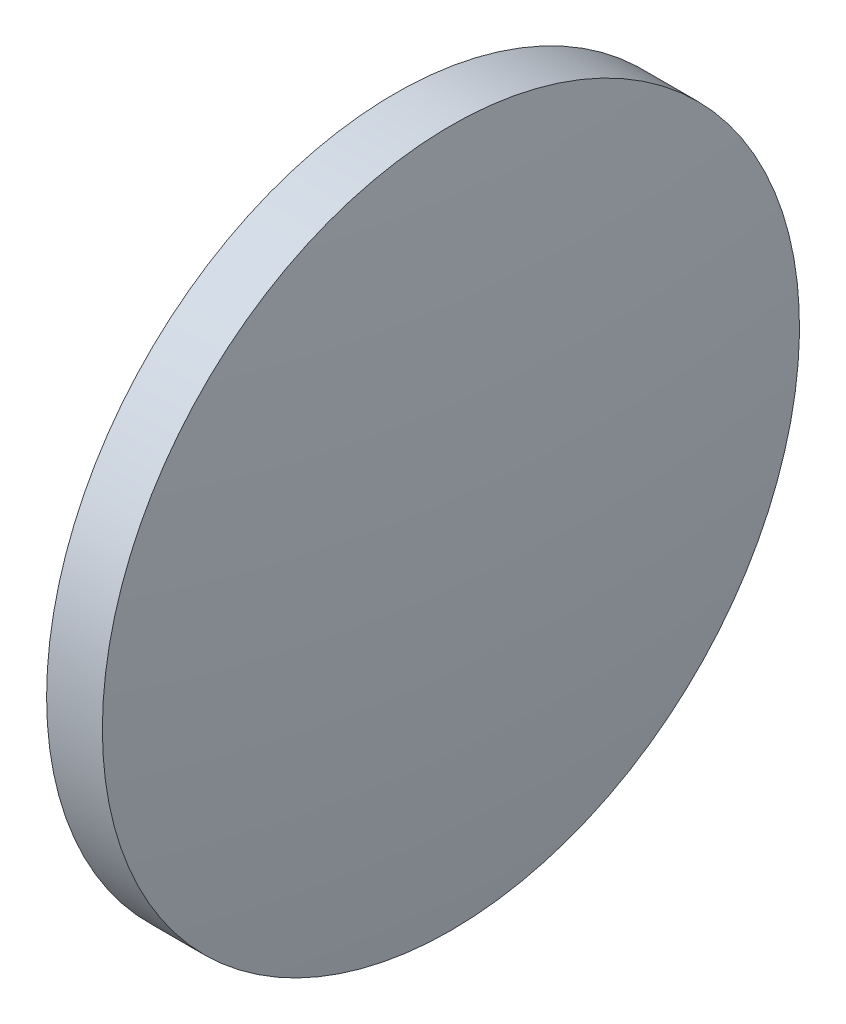
from build123d import *


with BuildPart() as part:
    # 草图1 → 旋转1 (revolve)
    with BuildSketch(Plane.XY, mode=Mode.PRIVATE) as revolve_1_sk:
        with BuildLine():
            Line((403.447923091, 108.251348429), (403.447923091, 120.751348429))
            Line((403.447923091, 120.751348429), (405.447923091, 120.751348429))
            ThreePointArc((405.447923091, 120.751348429), (406.017747824, 114.512889773), (406.207923091, 108.251348429))
            Line((406.207923091, 108.251348429), (403.447923091, 108.251348429))
        make_face()
    revolve(revolve_1_sk.sketch.rotate(Axis((401.082307188, 108.251348429, 0), (1, 0, 0)), 180), axis=Axis((401.082307188, 108.251348429, 0), (1, 0, 0)))  # turned: the seam where the file's is


solid = part.part
